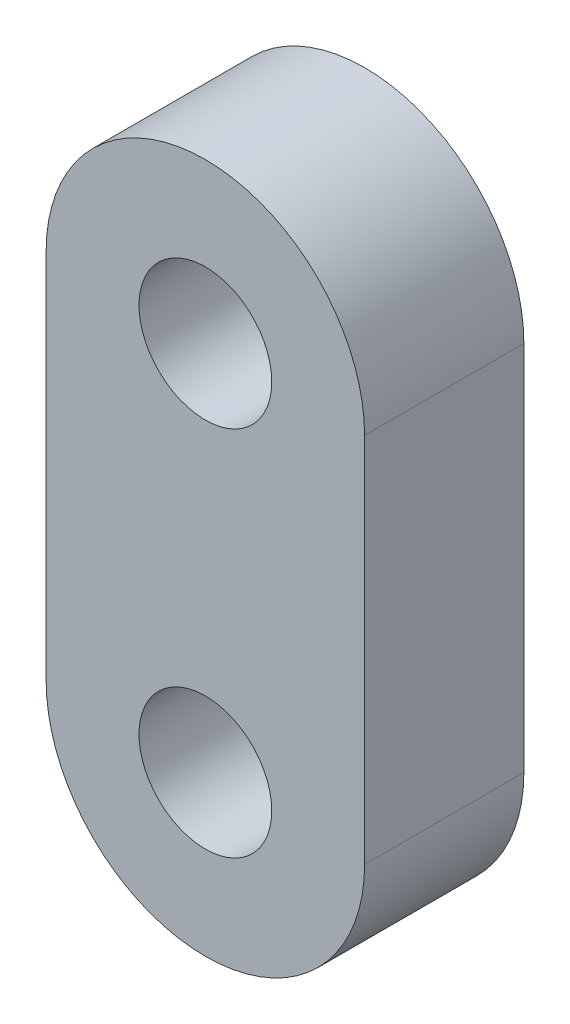
from build123d import *

# Parameters (mm, degrees)
SKETCH1_R           = 1.25
BOSS_EXTRUDE1_DEPTH = 3


with BuildPart() as part:
    # Sketch1 → Boss-Extrude1 (new body)
    with BuildSketch(Plane.XY):
        with BuildLine():
            Line((-3, 0), (-3, -7))
            ThreePointArc((-3, -7), (0, -10), (3, -7))
            Line((3, -7), (3, 0))
            ThreePointArc((3, 0), (0, 3), (-3, 0))
        make_face()
        Circle(SKETCH1_R, mode=Mode.SUBTRACT)
        with Locations((0, -7)):
            Circle(SKETCH1_R, mode=Mode.SUBTRACT)
    extrude(amount=BOSS_EXTRUDE1_DEPTH)


solid = part.part
